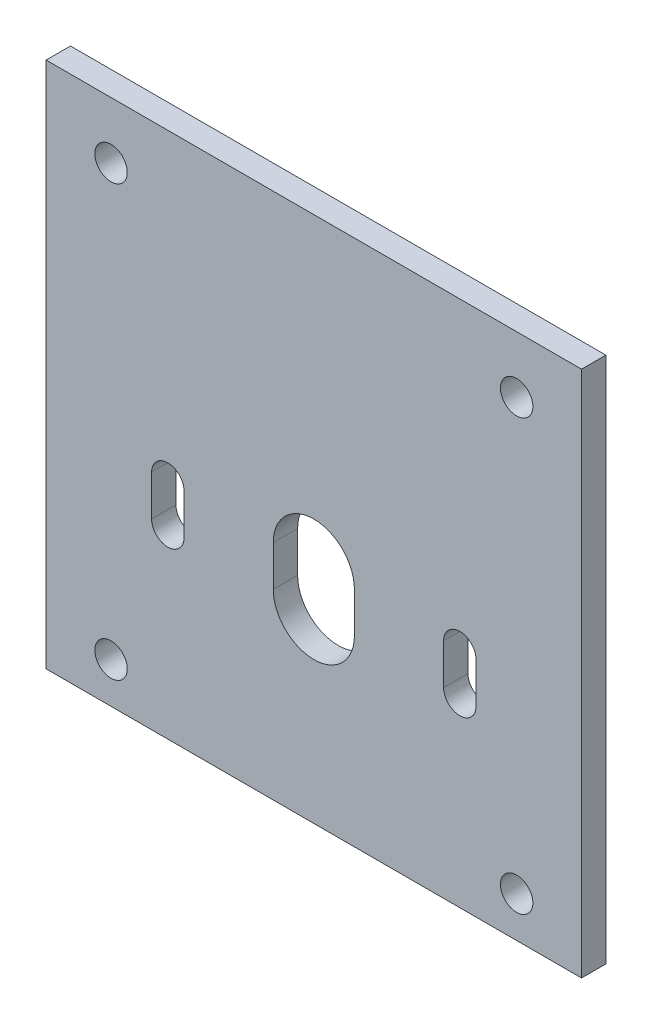
from build123d import *

# Parameters (mm, degrees)
SKETCH1_W           = 3
SKETCH1_H           = 65
BOSS_EXTRUDE1_DEPTH = 66
CUT_EXTRUDE3_REACH  = 5
SKETCH5_R           = 2


with BuildPart() as part:
    # Sketch1 → Boss-Extrude1 (new body)
    with BuildSketch(Plane(origin=(0, 0, 0), x_dir=(0, 0, -1), z_dir=(1, 0, 0))):
        with Locations((-1.5, -32.5)):
            Rectangle(SKETCH1_W, SKETCH1_H)
    extrude(amount=-BOSS_EXTRUDE1_DEPTH)

    # Sketch5 → Cut-Extrude3 (cut, up to next)
    with BuildSketch(Plane(origin=(0, 0, 0), x_dir=(-1, 0, 0), z_dir=(0, 0, -1)), mode=Mode.PRIVATE) as cut_extrude3_sk1:
        with Locations((8, -7)):
            Circle(SKETCH5_R)
    cut_extrude3_tool1 = extrude(cut_extrude3_sk1.sketch, amount=-CUT_EXTRUDE3_REACH, mode=Mode.PRIVATE) & part.part
    add(cut_extrude3_tool1.solids().sort_by_distance((-8, -7, 0))[0], mode=Mode.SUBTRACT)
    # Sketch5 → Cut-Extrude3 (cut, up to next)
    with BuildSketch(Plane(origin=(0, 0, 0), x_dir=(-1, 0, 0), z_dir=(0, 0, -1)), mode=Mode.PRIVATE) as cut_extrude3_sk2:
        with Locations((58, -7)):
            Circle(SKETCH5_R)
    cut_extrude3_tool2 = extrude(cut_extrude3_sk2.sketch, amount=-CUT_EXTRUDE3_REACH, mode=Mode.PRIVATE) & part.part
    add(cut_extrude3_tool2.solids().sort_by_distance((-58, -7, 0))[0], mode=Mode.SUBTRACT)
    # Sketch5 → Cut-Extrude3 (cut, up to next)
    with BuildSketch(Plane(origin=(0, 0, 0), x_dir=(-1, 0, 0), z_dir=(0, 0, -1)), mode=Mode.PRIVATE) as cut_extrude3_sk3:
        with Locations((8, -60)):
            Circle(SKETCH5_R)
    cut_extrude3_tool3 = extrude(cut_extrude3_sk3.sketch, amount=-CUT_EXTRUDE3_REACH, mode=Mode.PRIVATE) & part.part
    add(cut_extrude3_tool3.solids().sort_by_distance((-8, -60, 0))[0], mode=Mode.SUBTRACT)
    # Sketch5 → Cut-Extrude3 (cut, up to next)
    with BuildSketch(Plane(origin=(0, 0, 0), x_dir=(-1, 0, 0), z_dir=(0, 0, -1)), mode=Mode.PRIVATE) as cut_extrude3_sk4:
        with Locations((58, -60)):
            Circle(SKETCH5_R)
    cut_extrude3_tool4 = extrude(cut_extrude3_sk4.sketch, amount=-CUT_EXTRUDE3_REACH, mode=Mode.PRIVATE) & part.part
    add(cut_extrude3_tool4.solids().sort_by_distance((-58, -60, 0))[0], mode=Mode.SUBTRACT)
    # Sketch5 → Cut-Extrude3 (cut, up to next)
    with BuildSketch(Plane(origin=(0, 0, 0), x_dir=(-1, 0, 0), z_dir=(0, 0, -1)), mode=Mode.PRIVATE) as cut_extrude3_sk5:
        with BuildLine():
            Line((38, -37.5), (38, -42.5))
            ThreePointArc((38, -42.5), (33, -47.5), (28, -42.5))
            Line((28, -42.5), (28, -37.5))
            ThreePointArc((28, -37.5), (33, -32.5), (38, -37.5))
        make_face()
    cut_extrude3_tool5 = extrude(cut_extrude3_sk5.sketch, amount=-CUT_EXTRUDE3_REACH, mode=Mode.PRIVATE) & part.part
    add(cut_extrude3_tool5.solids().sort_by_distance((-33, -40, 0))[0], mode=Mode.SUBTRACT)
    # Sketch5 → Cut-Extrude3 (cut, up to next)
    with BuildSketch(Plane(origin=(0, 0, 0), x_dir=(-1, 0, 0), z_dir=(0, 0, -1)), mode=Mode.PRIVATE) as cut_extrude3_sk6:
        with BuildLine():
            Line((17, -37.5), (17, -42.5))
            ThreePointArc((17, -42.5), (15, -44.5), (13, -42.5))
            Line((13, -42.5), (13, -37.5))
            ThreePointArc((13, -37.5), (15, -35.5), (17, -37.5))
        make_face()
    cut_extrude3_tool6 = extrude(cut_extrude3_sk6.sketch, amount=-CUT_EXTRUDE3_REACH, mode=Mode.PRIVATE) & part.part
    add(cut_extrude3_tool6.solids().sort_by_distance((-15, -40, 0))[0], mode=Mode.SUBTRACT)
    # Sketch5 → Cut-Extrude3 (cut, up to next)
    with BuildSketch(Plane(origin=(0, 0, 0), x_dir=(-1, 0, 0), z_dir=(0, 0, -1)), mode=Mode.PRIVATE) as cut_extrude3_sk7:
        with BuildLine():
            Line((53, -37.5), (53, -42.5))
            ThreePointArc((53, -42.5), (51, -44.5), (49, -42.5))
            Line((49, -42.5), (49, -37.5))
            ThreePointArc((49, -37.5), (51, -35.5), (53, -37.5))
        make_face()
    cut_extrude3_tool7 = extrude(cut_extrude3_sk7.sketch, amount=-CUT_EXTRUDE3_REACH, mode=Mode.PRIVATE) & part.part
    add(cut_extrude3_tool7.solids().sort_by_distance((-51, -40, 0))[0], mode=Mode.SUBTRACT)


solid = part.part
